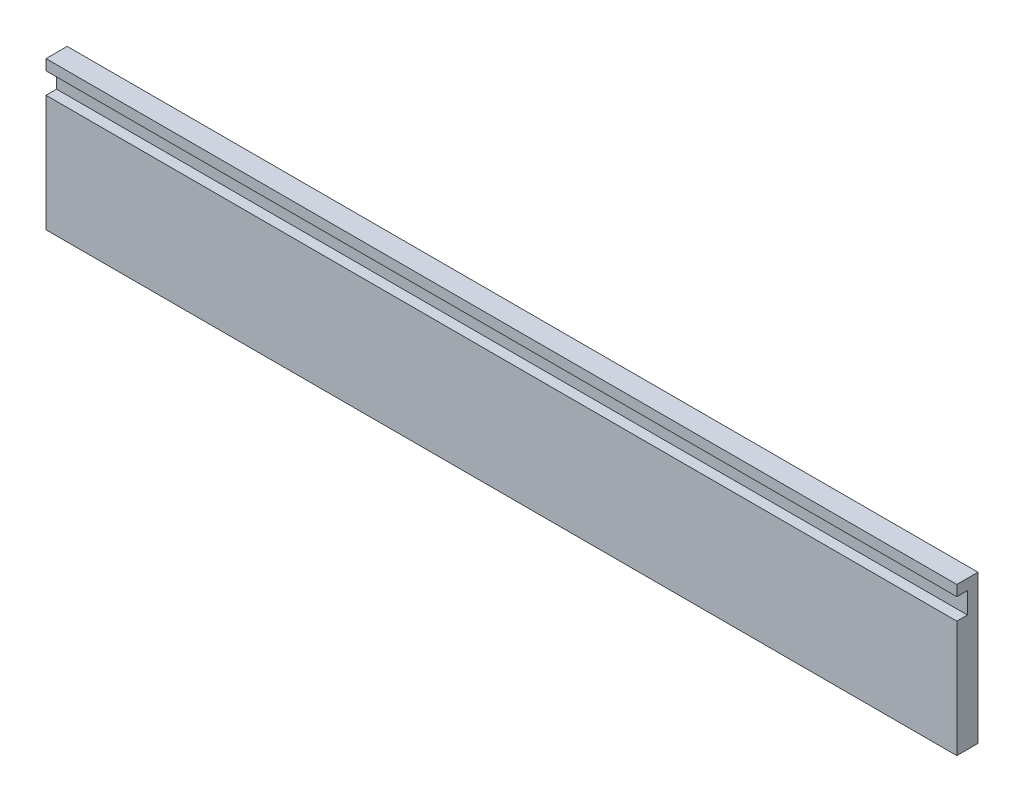
from build123d import *

# Parameters (mm, degrees)
SKETCH2_W           = 546.1
SKETCH2_H           = 88.9
BOSS_EXTRUDE1_DEPTH = 12.7
SKETCH3_W           = 546.1
SKETCH3_H           = 12.7
CUT_EXTRUDE1_DEPTH  = 6.35


with BuildPart() as part:
    # Sketch2 → Boss-Extrude1 (new body)
    with BuildSketch(Plane.XY):
        with Locations((58.612424242, 49.837878788)):
            Rectangle(SKETCH2_W, SKETCH2_H)
    extrude(amount=BOSS_EXTRUDE1_DEPTH)

    # Sketch3 → Cut-Extrude1 (cut)
    with BuildSketch(Plane.XY.offset(12.7)):
        with Locations((58.612424242, 81.587878788)):
            Rectangle(SKETCH3_W, SKETCH3_H)
    extrude(amount=-CUT_EXTRUDE1_DEPTH, mode=Mode.SUBTRACT)


solid = part.part
